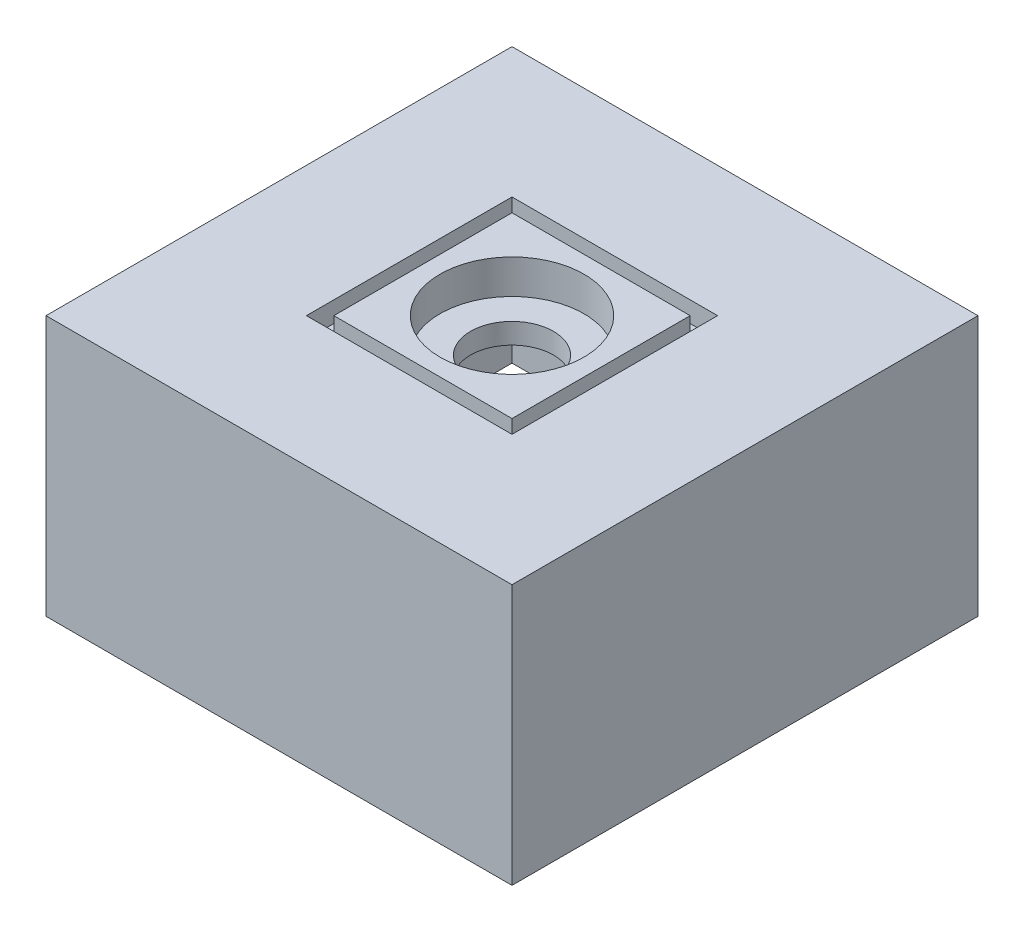
from build123d import *

# Parameters (mm, degrees)
SKETCH2_W           = 68
SKETCH2_H           = 68
BOSS_EXTRUDE1_DEPTH = 38
SKETCH3_W           = 64
SKETCH3_H           = 64
CUT_EXTRUDE1_DEPTH  = 30
SKETCH5_W           = 30
SKETCH5_H           = 30
SKETCH5_W_2         = 26
SKETCH5_H_2         = 26
CUT_EXTRUDE2_DEPTH  = 3
SKETCH6_R           = 6.05
CUT_EXTRUDE3_DEPTH  = 39
SKETCH7_R           = 10.5
CUT_EXTRUDE4_DEPTH  = 5
SKETCH8_R           = 1.5
CUT_EXTRUDE5_DEPTH  = 3
SKETCH9_R           = 2.5
BOSS_EXTRUDE2_DEPTH = 7.5
SKETCH10_R          = 1.5
BOSS_EXTRUDE3_DEPTH = 2
SKETCH11_R          = 2.5
BOSS_EXTRUDE4_DEPTH = 2


with BuildPart() as part:
    # Sketch2 → Boss-Extrude1 (new body)
    with BuildSketch(Plane(origin=(0, 0, 0), x_dir=(1, 0, 0), z_dir=(0, 1, 0))):
        with Locations((34, -34)):
            Rectangle(SKETCH2_W, SKETCH2_H)
    extrude(amount=BOSS_EXTRUDE1_DEPTH)

    # Sketch3 → Cut-Extrude1 (cut)
    with BuildSketch(Plane.XZ):
        with Locations((34, 34)):
            Rectangle(SKETCH3_W, SKETCH3_H)
    extrude(amount=-CUT_EXTRUDE1_DEPTH, mode=Mode.SUBTRACT)

    # Sketch5 → Cut-Extrude2 (cut)
    with BuildSketch(Plane(origin=(0, 38, 0), x_dir=(1, 0, 0), z_dir=(0, 1, 0))):
        with Locations((34, -34)):
            Rectangle(SKETCH5_W, SKETCH5_H)
        with Locations((34, -34)):
            Rectangle(SKETCH5_W_2, SKETCH5_H_2, mode=Mode.SUBTRACT)
    extrude(amount=-CUT_EXTRUDE2_DEPTH, mode=Mode.SUBTRACT)

    # Sketch6 → Cut-Extrude3 (cut, through all)
    with BuildSketch(Plane(origin=(0, 38, 0), x_dir=(1, 0, 0), z_dir=(0, 1, 0))):
        with Locations((34, -34)):
            Circle(SKETCH6_R)
    extrude(amount=-CUT_EXTRUDE3_DEPTH, mode=Mode.SUBTRACT)

    # Sketch7 → Cut-Extrude4 (cut)
    with BuildSketch(Plane(origin=(0, 38, 0), x_dir=(1, 0, 0), z_dir=(0, 1, 0))):
        with Locations((34, -34)):
            Circle(SKETCH7_R)
    extrude(amount=-CUT_EXTRUDE4_DEPTH, mode=Mode.SUBTRACT)

    # Sketch8 → Cut-Extrude5 (cut, through all)
    with BuildSketch(Plane.XY.offset(2)):
        with Locations((56, 5)):
            Circle(SKETCH8_R)
    extrude(amount=-CUT_EXTRUDE5_DEPTH, mode=Mode.SUBTRACT)

    # Sketch9 → Boss-Extrude2 (add)
    with BuildSketch(Plane.XZ.offset(-30)):
        with Locations((10, 58)):
            Circle(SKETCH9_R)
    extrude(amount=BOSS_EXTRUDE2_DEPTH)

    # Sketch10 → Boss-Extrude3 (add)
    with BuildSketch(Plane.XZ.offset(-22.5)):
        with Locations((10, 58)):
            Circle(SKETCH10_R)
    extrude(amount=BOSS_EXTRUDE3_DEPTH)

    # Sketch11 → Boss-Extrude4 (add)
    with BuildSketch(Plane.XZ.offset(-20.5)):
        with Locations((10, 58)):
            Circle(SKETCH11_R)
    extrude(amount=BOSS_EXTRUDE4_DEPTH)


solid = part.part
